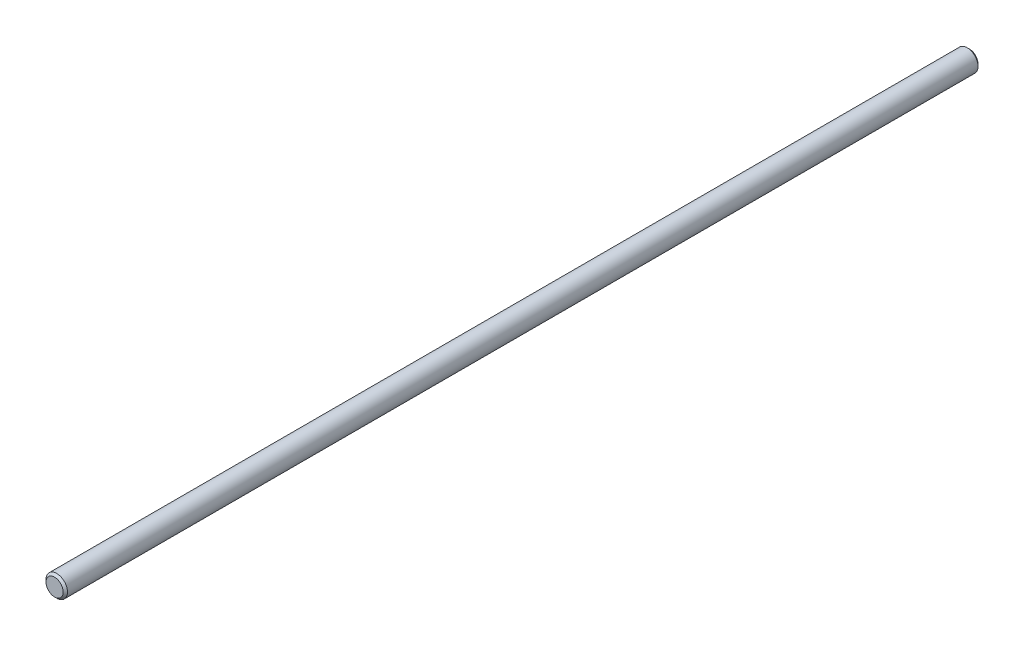
from build123d import *

# Parameters (mm, degrees)
SKETCH1_R      = 5
EXTRUDE1_DEPTH = 213.106
CHAMFER1_SIZE  = 1


with BuildPart() as part:
    # Sketch1 → Extrude1 (new body, symmetric)
    with BuildSketch(Plane.XY):
        Circle(SKETCH1_R)
    extrude(amount=EXTRUDE1_DEPTH, both=True)

    # Chamfer1
    chamfer1_edges = [part.edges().sort_by_distance(p)[0] for p in [
        (-5, 0, -213.106),
        (-5, 0, 213.106),
    ]]
    chamfer(chamfer1_edges, length=CHAMFER1_SIZE)


solid = part.part
